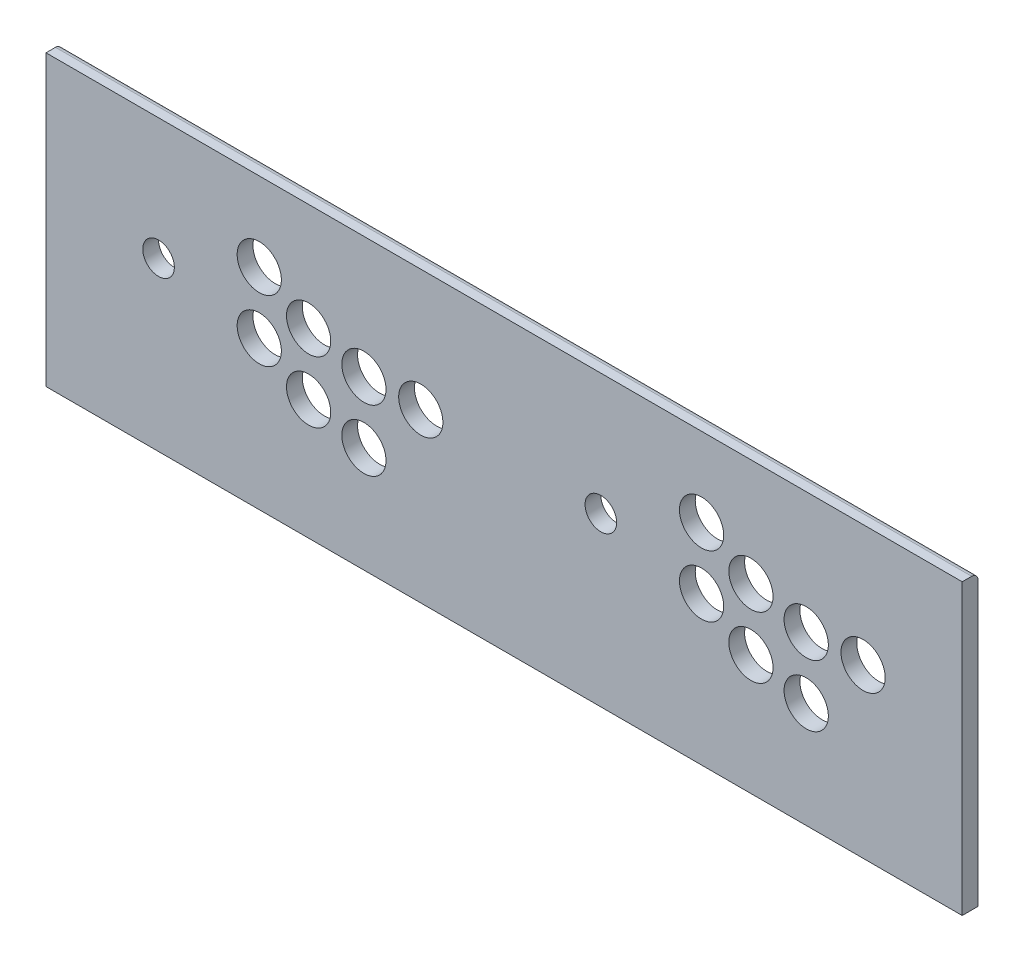
from build123d import *

# Parameters (mm, degrees)
ESQUISSE1_W                = 580
ESQUISSE1_H                = 183
BOSS_EXTRU_1_DEPTH         = 10
ESQUISSE3_R                = 14
ESQUISSE3_R_2              = 10
ENL_V_MAT_EXTRU_1_DEPTH    = 10
R_P_TITION_LIN_AIRE1_COUNT = 2
R_P_TITION_LIN_AIRE1_PITCH = 280
CONG_1_R                   = 4


with BuildPart() as part:
    # Esquisse1 → Boss.-Extru.1 (new body)
    with BuildSketch(Plane.XY):
        with Locations((290, 91.5)):
            Rectangle(ESQUISSE1_W, ESQUISSE1_H)
    extrude(amount=BOSS_EXTRU_1_DEPTH)

    # Esquisse3 → Enlèv. mat.-Extru.1 (cut)
    with BuildSketch(Plane(origin=(0, 0, 0), x_dir=(-1, 0, 0), z_dir=(0, 0, -1))):
        with Locations((-201.25, 67)):
            Circle(ESQUISSE3_R)
        with Locations((-71.25, 106)):
            Circle(ESQUISSE3_R_2)
        with Locations((-166.25, 76)):
            Circle(ESQUISSE3_R)
        with Locations((-135, 94)):
            Circle(ESQUISSE3_R)
        with Locations((-237.25, 106)):
            Circle(ESQUISSE3_R)
        with Locations((-201.25, 106)):
            Circle(ESQUISSE3_R)
        with Locations((-166.25, 115)):
            Circle(ESQUISSE3_R)
        with Locations((-135, 133)):
            Circle(ESQUISSE3_R)
    enl_v_mat_extru_1 = extrude(amount=-ENL_V_MAT_EXTRU_1_DEPTH, mode=Mode.SUBTRACT)

    # Répétition linéaire1: Enlèv. mat.-Extru.1 ×2
    with Locations(*[(i * R_P_TITION_LIN_AIRE1_PITCH, 0, 0) for i in range(1, R_P_TITION_LIN_AIRE1_COUNT)]):
        add(enl_v_mat_extru_1, mode=Mode.SUBTRACT)

    # Congé1
    cong_1_edges = [part.edges().sort_by_distance(p)[0] for p in [
        (290, 183, 0),
    ]]
    fillet(cong_1_edges, radius=CONG_1_R)


solid = part.part
